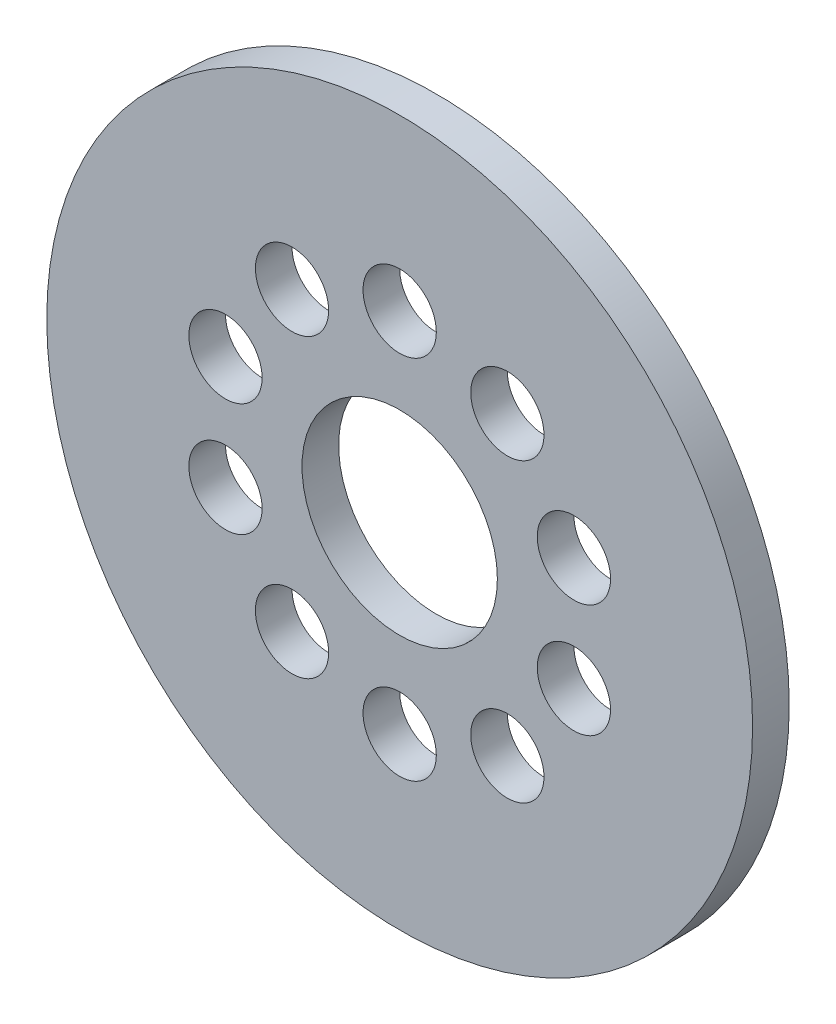
from build123d import *

# Parameters (mm, degrees)
SKETCH2_R           = 144.505
BOSS_EXTRUDE1_DEPTH = 7.5
SKETCH3_R           = 40
SKETCH3_R_2         = 15
CUT_EXTRUDE1_DEPTH  = 16


with BuildPart() as part:
    # Sketch2 → Boss-Extrude1 (new body, symmetric)
    with BuildSketch(Plane.XY):
        Circle(SKETCH2_R)
    extrude(amount=BOSS_EXTRUDE1_DEPTH, both=True)

    # Sketch3 → Cut-Extrude1 (cut, through all)
    with BuildSketch(Plane.XY.offset(7.5)):
        Circle(SKETCH3_R)
        with Locations((0, 75)):
            Circle(SKETCH3_R_2)
        with Locations((44.083893922, 60.676274578)):
            Circle(SKETCH3_R_2)
        with Locations((71.329238722, 23.176274578)):
            Circle(SKETCH3_R_2)
        with Locations((71.329238722, -23.176274578)):
            Circle(SKETCH3_R_2)
        with Locations((44.083893922, -60.676274578)):
            Circle(SKETCH3_R_2)
        with Locations((0, -75)):
            Circle(SKETCH3_R_2)
        with Locations((-44.083893922, -60.676274578)):
            Circle(SKETCH3_R_2)
        with Locations((-71.329238722, -23.176274578)):
            Circle(SKETCH3_R_2)
        with Locations((-71.329238722, 23.176274578)):
            Circle(SKETCH3_R_2)
        with Locations((-44.083893922, 60.676274578)):
            Circle(SKETCH3_R_2)
    extrude(amount=-CUT_EXTRUDE1_DEPTH, mode=Mode.SUBTRACT)


solid = part.part
